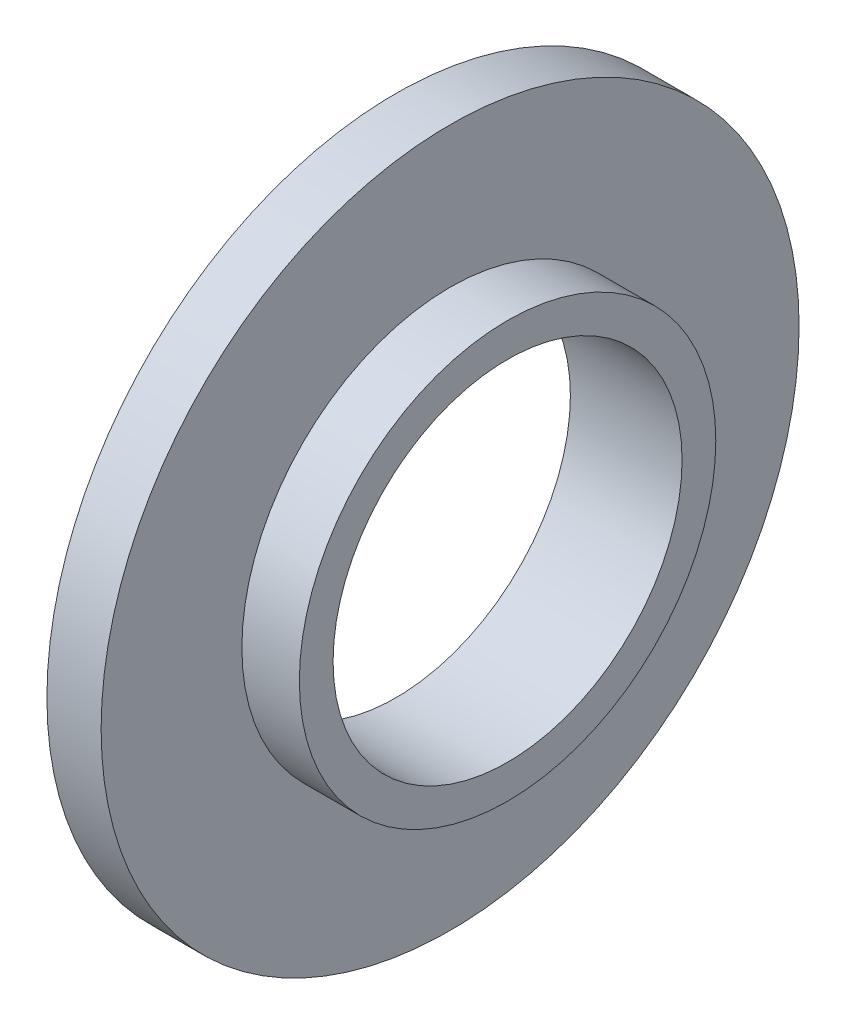
from build123d import *

# Parameters (mm, degrees)
SKETCH_1_R          = 30
EXTRUDE_1_DEPTH     = 4.66
SKETCH_2_R          = 17.9
EXTRUDE_2_DEPTH     = 4.94
SKETCH_3_R          = 15
CUT_EXTRUDE_1_DEPTH = 10.6


with BuildPart() as part:
    # 草图1 → 凸台-拉伸1 (new body)
    with BuildSketch(Plane(origin=(0, 0, 0), x_dir=(0, 0, -1), z_dir=(1, 0, 0))):
        Circle(SKETCH_1_R)
    extrude(amount=EXTRUDE_1_DEPTH)

    # 草图2 → 凸台-拉伸2 (add)
    with BuildSketch(Plane(origin=(4.66, 0, 0), x_dir=(0, 0, -1), z_dir=(1, 0, 0))):
        Circle(SKETCH_2_R)
    extrude(amount=EXTRUDE_2_DEPTH)

    # 草图3 → 切除-拉伸1 (cut, through all)
    with BuildSketch(Plane(origin=(9.6, 0, 0), x_dir=(0, 0, -1), z_dir=(1, 0, 0))):
        Circle(SKETCH_3_R)
    extrude(amount=-CUT_EXTRUDE_1_DEPTH, mode=Mode.SUBTRACT)


solid = part.part
